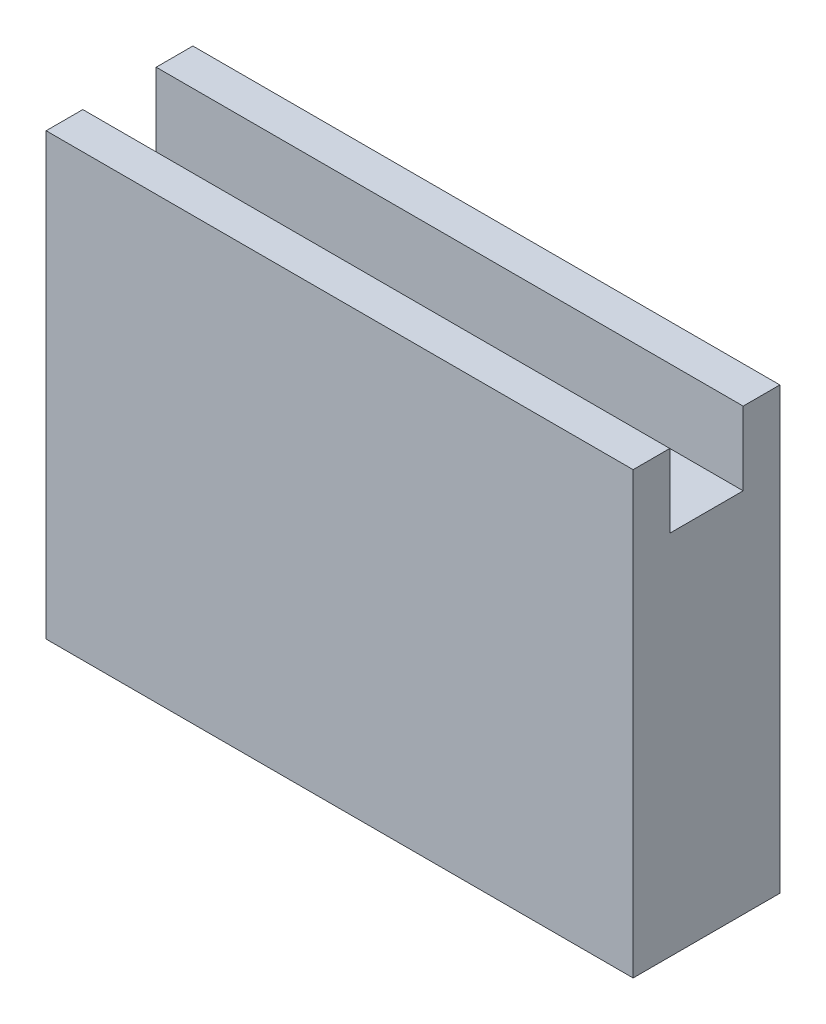
from build123d import *

# Parameters (mm, degrees)
SKETCH1_W           = 50.8
SKETCH1_H           = 12.7
BOSS_EXTRUDE1_DEPTH = 31.75
SKETCH2_W           = 50.8
SKETCH2_H           = 3.175
BOSS_EXTRUDE2_DEPTH = 6.35


with BuildPart() as part:
    # Sketch1 → Boss-Extrude1 (new body)
    with BuildSketch(Plane(origin=(0, 0, 0), x_dir=(1, 0, 0), z_dir=(0, 1, 0))):
        Rectangle(SKETCH1_W, SKETCH1_H)
    extrude(amount=BOSS_EXTRUDE1_DEPTH)

    # Sketch2 → Boss-Extrude2 (add)
    with BuildSketch(Plane(origin=(0, 31.75, 0), x_dir=(1, 0, 0), z_dir=(0, 1, 0))):
        with Locations((0, -4.7625)):
            Rectangle(SKETCH2_W, SKETCH2_H)
        with Locations((0, 4.7625)):
            Rectangle(SKETCH2_W, SKETCH2_H)
    extrude(amount=BOSS_EXTRUDE2_DEPTH)


solid = part.part
